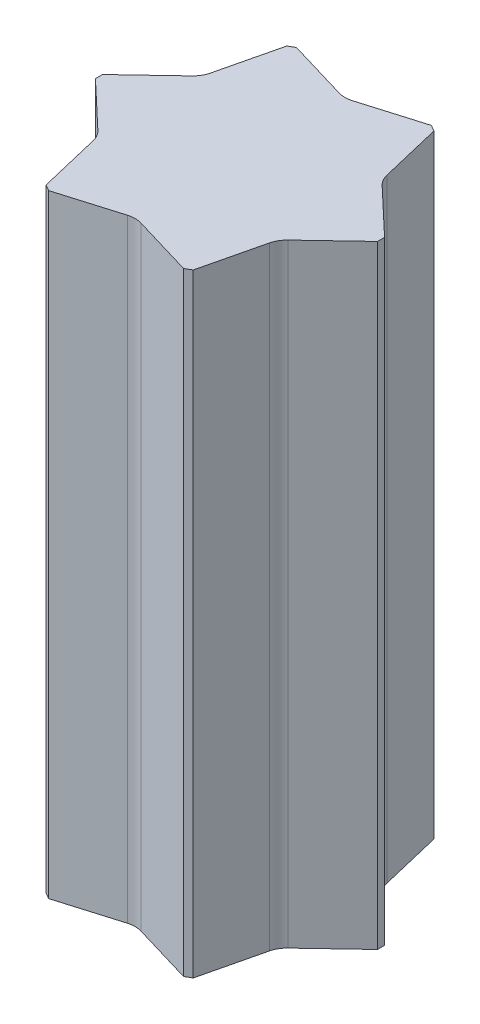
from build123d import *

# Parameters (mm, degrees)
EXTRUDE_1_DEPTH     = 1500
CUT_EXTRUDE_4_DEPTH = 1500
SHELL_3_T           = 10


with BuildPart() as part:
    # 草图2 → 凸台-拉伸1 (new body)
    with BuildSketch(Plane(origin=(0, 0, 0), x_dir=(1, 0, 0), z_dir=(0, 1, 0))):
        Polygon((345, 8.660254038), (180, 294.448637287), (165, 303.108891325), (-165, 303.108891325), (-180, 294.448637287), (-345, 8.660254038), (-345, -8.660254038), (-180, -294.448637287), (-165, -303.108891325), (165, -303.108891325), (180, -294.448637287), (345, -8.660254038), align=None)
    extrude(amount=EXTRUDE_1_DEPTH)

    # 草图5 → 切除-拉伸4 (cut)
    with BuildSketch(Plane(origin=(0, 0, 0), x_dir=(1, 0, 0), z_dir=(0, 1, 0))):
        with BuildLine():
            Line((165, 303.108891325), (16.245071573, 258.879313504))
            ThreePointArc((16.245071573, 258.879313504), (0, 256.515365505), (-16.245071573, 258.879313504))
            Line((-16.245071573, 258.879313504), (-165, 303.108891325))
            Line((-165, 303.108891325), (-165, 323.92213511))
            Line((-165, 323.92213511), (-16.245047342, 368.151648331))
            ThreePointArc((-16.245047342, 368.151648331), (0, 370.515589126), (16.245047342, 368.151648331))
            Line((16.245047342, 368.151648331), (165, 323.92213511))
            Line((165, 323.92213511), (165, 303.108891325))
        make_face()
        with BuildLine():
            Line((198.024797853, 304.855259179), (310.706156229, 198.14444785))
            ThreePointArc((310.706156229, 198.14444785), (320.875912682, 185.257794563), (326.951203571, 170.007200482))
            Line((326.951203571, 170.007200482), (363.024797853, 19.06687593))
            Line((363.024797853, 19.06687593), (345, 8.660254038))
            Line((345, 8.660254038), (232.318597795, 115.371012084))
            ThreePointArc((232.318597795, 115.371012084), (222.148822988, 128.257682752), (216.073526222, 143.50830142))
            Line((216.073526222, 143.50830142), (180, 294.448637287))
            Line((180, 294.448637287), (198.024797853, 304.855259179))
        make_face()
        with BuildLine():
            Line((363.024797853, -19.06687593), (326.951203571, -170.007200482))
            ThreePointArc((326.951203571, -170.007200482), (320.875912682, -185.257794563), (310.706156229, -198.14444785))
            Line((310.706156229, -198.14444785), (198.024797853, -304.855259179))
            Line((198.024797853, -304.855259179), (180, -294.448637287))
            Line((180, -294.448637287), (216.073526222, -143.50830142))
            ThreePointArc((216.073526222, -143.50830142), (222.148822988, -128.257682752), (232.318597795, -115.371012084))
            Line((232.318597795, -115.371012084), (345, -8.660254038))
            Line((345, -8.660254038), (363.024797853, -19.06687593))
        make_face()
        with BuildLine():
            Line((165, -323.92213511), (16.245047342, -368.151648331))
            ThreePointArc((16.245047342, -368.151648331), (0, -370.515589126), (-16.245047342, -368.151648331))
            Line((-16.245047342, -368.151648331), (-165, -323.92213511))
            Line((-165, -323.92213511), (-165, -303.108891325))
            Line((-165, -303.108891325), (-16.245071573, -258.879313504))
            ThreePointArc((-16.245071573, -258.879313504), (0, -256.515365505), (16.245071573, -258.879313504))
            Line((16.245071573, -258.879313504), (165, -303.108891325))
            Line((165, -303.108891325), (165, -323.92213511))
        make_face()
        with BuildLine():
            Line((-198.024797853, -304.855259179), (-310.706156229, -198.14444785))
            ThreePointArc((-310.706156229, -198.14444785), (-320.875912682, -185.257794563), (-326.951203571, -170.007200482))
            Line((-326.951203571, -170.007200482), (-363.024797853, -19.06687593))
            Line((-363.024797853, -19.06687593), (-345, -8.660254038))
            Line((-345, -8.660254038), (-232.318597795, -115.371012084))
            ThreePointArc((-232.318597795, -115.371012084), (-222.148822988, -128.257682752), (-216.073526222, -143.50830142))
            Line((-216.073526222, -143.50830142), (-180, -294.448637287))
            Line((-180, -294.448637287), (-198.024797853, -304.855259179))
        make_face()
        with BuildLine():
            Line((-363.024797853, 19.06687593), (-326.951203571, 170.007200482))
            ThreePointArc((-326.951203571, 170.007200482), (-320.875912682, 185.257794563), (-310.706156229, 198.14444785))
            Line((-310.706156229, 198.14444785), (-198.024797853, 304.855259179))
            Line((-198.024797853, 304.855259179), (-180, 294.448637287))
            Line((-180, 294.448637287), (-216.073526222, 143.50830142))
            ThreePointArc((-216.073526222, 143.50830142), (-222.148822988, 128.257682752), (-232.318597795, 115.371012084))
            Line((-232.318597795, 115.371012084), (-345, 8.660254038))
            Line((-345, 8.660254038), (-363.024797853, 19.06687593))
        make_face()
    extrude(amount=CUT_EXTRUDE_4_DEPTH, mode=Mode.SUBTRACT)

    # 抽壳3 (no face opened: a closed hollow body)
    add(offset(amount=-SHELL_3_T, mode=Mode.PRIVATE), mode=Mode.SUBTRACT)


solid = part.part
